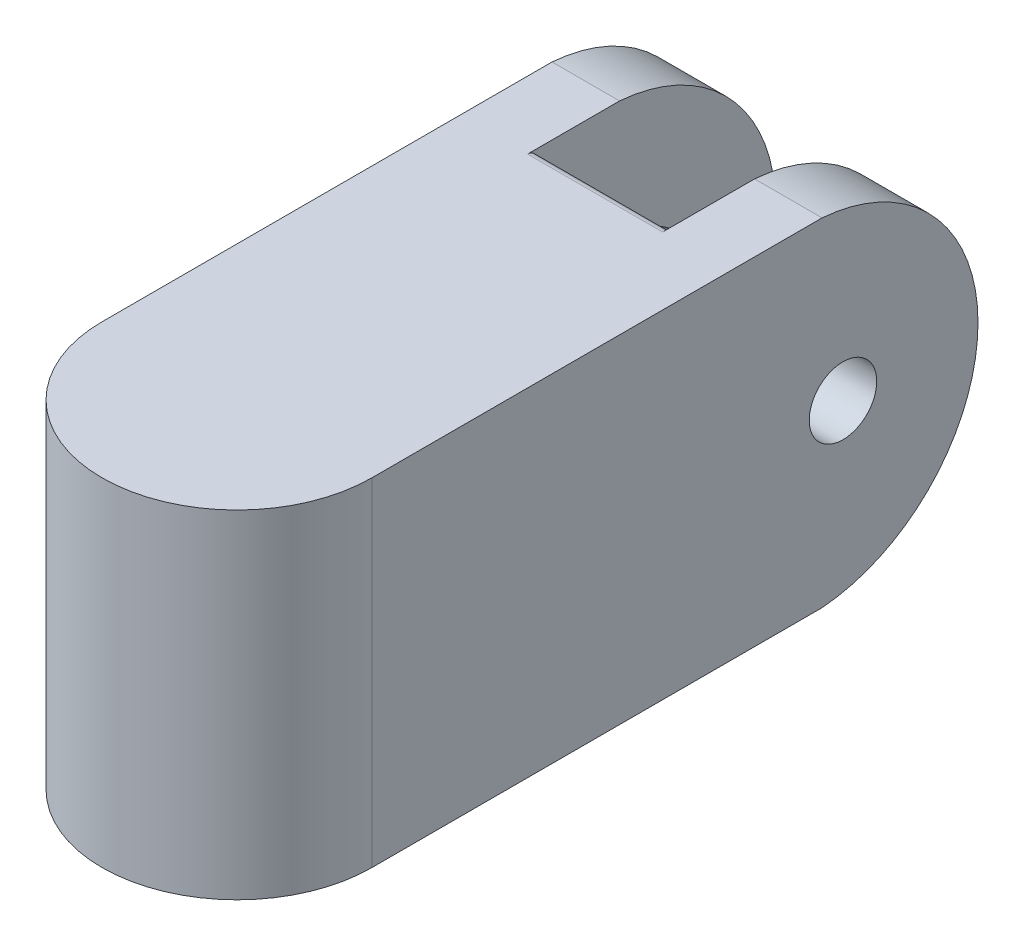
from build123d import *

# Parameters (mm, degrees)
SKETCH1_W                                       = 15.24
SKETCH1_H                                       = 19.05
BOSS_EXTRUDE1_DEPTH                             = 25.4
BOSS_EXTRUDE5_DEPTH                             = 3.81
LPATTERN2_COUNT                                 = 2
LPATTERN2_PITCH                                 = 11.43
SKETCH10_R                                      = 1.905
CUT_EXTRUDE1_DEPTH                              = 16.24
BOSS_EXTRUDE6_DEPTH                             = 19.05
CUT_EXTRUDE2_DEPTH                              = 3.81
CBORE_FOR_6_PAN_HEAD_MACHINE_SCREW1_D           = 3.7500052
CBORE_FOR_6_PAN_HEAD_MACHINE_SCREW1_CBORE_D     = 7.5000104
CBORE_FOR_6_PAN_HEAD_MACHINE_SCREW1_CBORE_DEPTH = 2.032
CUT_EXTRUDE3_REACH                              = 15.208
SKETCH22_R                                      = 2.499995
FILLET1_R                                       = 0.5
FILLET2_R                                       = 0.5
CUT_EXTRUDE4_DEPTH                              = 1.27
CUT_EXTRUDE6_DEPTH                              = 3.048
FILLET3_R                                       = 0.5
CUT_EXTRUDE7_DEPTH                              = 1.27
SKETCH27_R                                      = 1.397
CUT_EXTRUDE8_DEPTH                              = 1.27


with BuildPart() as part:
    # Sketch1 → Boss-Extrude1 (new body)
    with BuildSketch(Plane.XY):
        Rectangle(SKETCH1_W, SKETCH1_H)
    extrude(amount=BOSS_EXTRUDE1_DEPTH)

    # Sketch9 → Boss-Extrude5 (add)
    with BuildSketch(Plane(origin=(7.62, 0, 0), x_dir=(0, 0, -1), z_dir=(1, 0, 0))):
        with BuildLine():
            Line((0, 9.525), (0, -9.525))
            ThreePointArc((0, -9.525), (8.798459024, 0), (0, 9.525))
        make_face()
    boss_extrude5 = extrude(amount=-BOSS_EXTRUDE5_DEPTH)

    # LPattern2: Boss-Extrude5 ×2
    with Locations(*[(-i * LPATTERN2_PITCH, 0, 0) for i in range(1, LPATTERN2_COUNT)]):
        add(boss_extrude5)

    # Sketch10 → Cut-Extrude1 (cut, through all)
    with BuildSketch(Plane(origin=(7.62, 0, 0), x_dir=(0, 0, -1), z_dir=(1, 0, 0))):
        with Locations((1.178459024, 0)):
            Circle(SKETCH10_R)
    extrude(amount=-CUT_EXTRUDE1_DEPTH, mode=Mode.SUBTRACT)

    # Sketch13 → Boss-Extrude6 (add)
    with BuildSketch(Plane(origin=(0, -9.525, 0), x_dir=(-1, 0, 0), z_dir=(0, -1, 0))):
        with BuildLine():
            Line((7.62, -25.4), (-7.62, -25.4))
            ThreePointArc((-7.62, -25.4), (0, -33.02), (7.62, -25.4))
        make_face()
    extrude(amount=-BOSS_EXTRUDE6_DEPTH)

    # Sketch17 → Cut-Extrude2 (cut, symmetric)
    with BuildSketch(Plane(origin=(0, 0, 0), x_dir=(0, 0, -1), z_dir=(1, 0, 0))):
        with BuildLine():
            Line((0, 9.525), (0, -9.525))
            ThreePointArc((0, -9.525), (-10.311535776, 0), (0, 9.525))
        make_face()
    extrude(amount=CUT_EXTRUDE2_DEPTH, both=True, mode=Mode.SUBTRACT)

    # CBORE for #6 Pan Head Machine Screw1 (through all)
    with Locations(Plane.ZY.offset(7.62)):
        with Locations((-1.178459024, 0)):
            CounterBoreHole(CBORE_FOR_6_PAN_HEAD_MACHINE_SCREW1_D / 2, CBORE_FOR_6_PAN_HEAD_MACHINE_SCREW1_CBORE_D / 2, CBORE_FOR_6_PAN_HEAD_MACHINE_SCREW1_CBORE_DEPTH)

    # Sketch22 → Cut-Extrude3 (cut, up to next)
    with BuildSketch(Plane.ZY.offset(5.588), mode=Mode.PRIVATE) as cut_extrude3_sk1:
        with Locations((-1.178459024, 0)):
            Circle(SKETCH22_R)
    cut_extrude3_tool1 = extrude(cut_extrude3_sk1.sketch, amount=-CUT_EXTRUDE3_REACH, mode=Mode.PRIVATE) & part.part
    add(cut_extrude3_tool1.solids().sort_by_distance((-5.588, 0, -1.178459))[0], mode=Mode.SUBTRACT)

    # Fillet1
    fillet1_edges = [part.edges().sort_by_distance(p)[0] for p in [
        (0, 9.525, 1.513076752),
        (0, -9.525, 1.513076752),
    ]]
    fillet(fillet1_edges, radius=FILLET1_R)

    # Fillet2
    fillet2_edges = [part.edges().sort_by_distance(p)[0] for p in [
        (-7.62, 0, -4.928464224),
        (-5.588, 0, -4.928464224),
    ]]
    fillet(fillet2_edges, radius=FILLET2_R)

    # Sketch18 → Cut-Extrude4 (cut)
    with BuildSketch(Plane(origin=(0, -9.525, 0), x_dir=(-1, 0, 0), z_dir=(0, -1, 0))):
        with BuildLine():
            Line((3.044880057, -17.007076752), (6.854880057, -17.007076752))
            ThreePointArc((6.854880057, -17.007076752), (6.332307247, -16.11715703), (6.858, -15.229076752))
            Line((6.858, -15.229076752), (1.778, -15.229076752))
            Line((1.778, -15.229076752), (1.778, -1.513076752))
            ThreePointArc((1.778, -1.513076752), (0, -3.291076752), (-1.778, -1.513076752))
            Line((-1.778, -1.513076752), (-1.778, -15.229076752))
            Line((-1.778, -15.229076752), (-6.858, -15.229076752))
            ThreePointArc((-6.858, -15.229076752), (-6.111619184, -16.118076752), (-6.858, -17.007076752))
            Line((-6.858, -17.007076752), (-3.048, -17.007076752))
            ThreePointArc((-3.048, -17.007076752), (-5.392804187, -22.012637101), (-5.614223517, -27.535744431))
            ThreePointArc((-5.614223517, -27.535744431), (-0.211295876, -32.163939746), (5.357263796, -27.736416493))
            ThreePointArc((5.357263796, -27.736416493), (5.298057191, -22.135324722), (3.044880057, -17.007076752))
        make_face()
    extrude(amount=-CUT_EXTRUDE4_DEPTH, mode=Mode.SUBTRACT)

    # Sketch23 → Cut-Extrude6 (cut)
    with BuildSketch(Plane.XZ.offset(9.525)):
        with BuildLine():
            Line((0, 19.008349223), (-3.846708267, 27.023019242))
            ThreePointArc((-3.846708267, 27.023019242), (-0.048818705, 29.690299102), (3.773291733, 27.057844207))
            Line((3.773291733, 27.057844207), (0, 19.008349223))
        make_face()
    extrude(amount=-CUT_EXTRUDE6_DEPTH, mode=Mode.SUBTRACT)

    # Fillet3
    fillet3_edges = [part.edges().sort_by_distance(p)[0] for p in [
        (0, -8.255, 5.568289649),
    ]]
    fillet(fillet3_edges, radius=FILLET3_R)

    # Sketch26 → Cut-Extrude7 (cut)
    with BuildSketch(Plane(origin=(0, -6.477, 0), x_dir=(-1, 0, 0), z_dir=(0, -1, 0))):
        with BuildLine():
            ThreePointArc((2.342289249, -26.290868459), (0.056289249, -28.576868459), (-2.229710751, -26.290868459))
            ThreePointArc((-2.229710751, -26.290868459), (0.056289249, -25.258930958), (2.342289249, -26.290868459))
        make_face()
    extrude(amount=-CUT_EXTRUDE7_DEPTH, mode=Mode.SUBTRACT)

    # Sketch27 → Cut-Extrude8 (cut)
    with BuildSketch(Plane.XZ.offset(5.207)):
        with Locations(Location((-0.056289249, 26.290868459, 0), (0, 0, 270))):  # turned: the seam where the file's is
            Circle(SKETCH27_R)
    extrude(amount=-CUT_EXTRUDE8_DEPTH, mode=Mode.SUBTRACT)


solid = part.part
